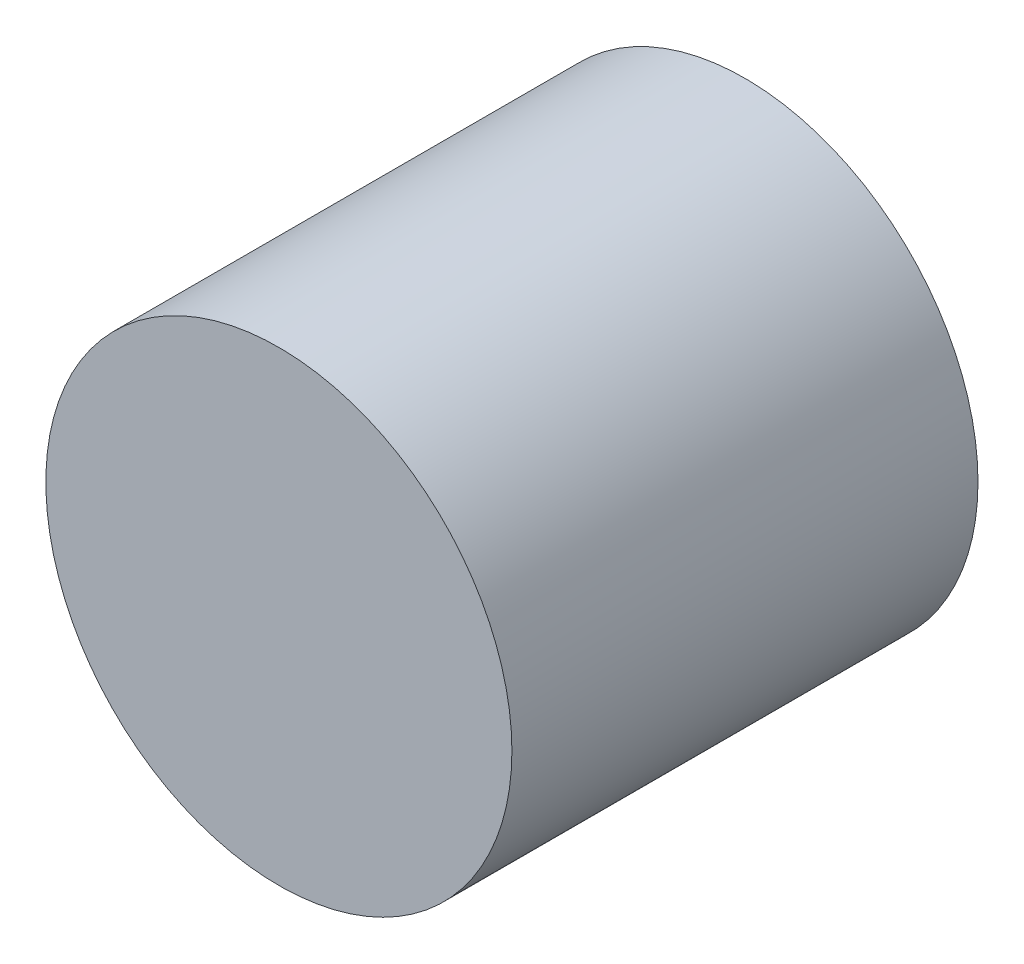
from build123d import *

# Parameters (mm, degrees)
SKETCH1_R           = 25
BOSS_EXTRUDE1_DEPTH = 50


with BuildPart() as part:
    # Sketch1 → Boss-Extrude1 (new body)
    with BuildSketch(Plane.XY):
        Circle(SKETCH1_R)
    extrude(amount=-BOSS_EXTRUDE1_DEPTH)


solid = part.part
